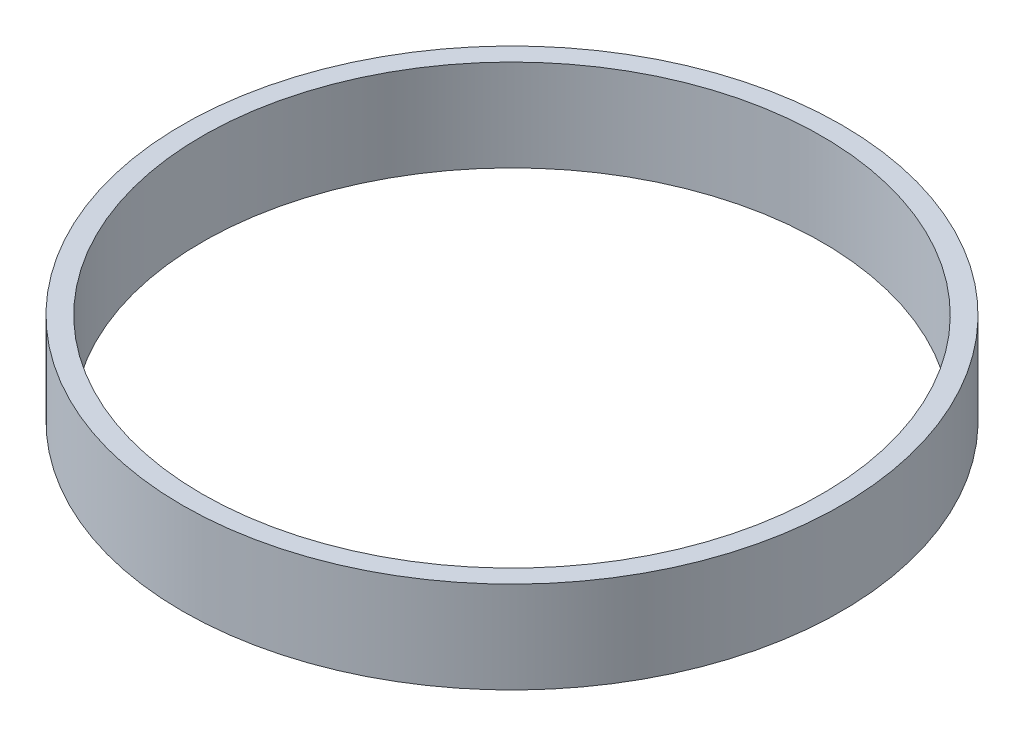
from build123d import *

# Parameters (mm, degrees)
SKETCH1_R           = 79.883
SKETCH1_R_2         = 75.1205
BOSS_EXTRUDE1_DEPTH = 22.225


with BuildPart() as part:
    # Sketch1 → Boss-Extrude1 (new body)
    with BuildSketch(Plane(origin=(0, 0, 0), x_dir=(1, 0, 0), z_dir=(0, 1, 0))):
        Circle(SKETCH1_R)
        Circle(SKETCH1_R_2, mode=Mode.SUBTRACT)
    extrude(amount=BOSS_EXTRUDE1_DEPTH)


solid = part.part
